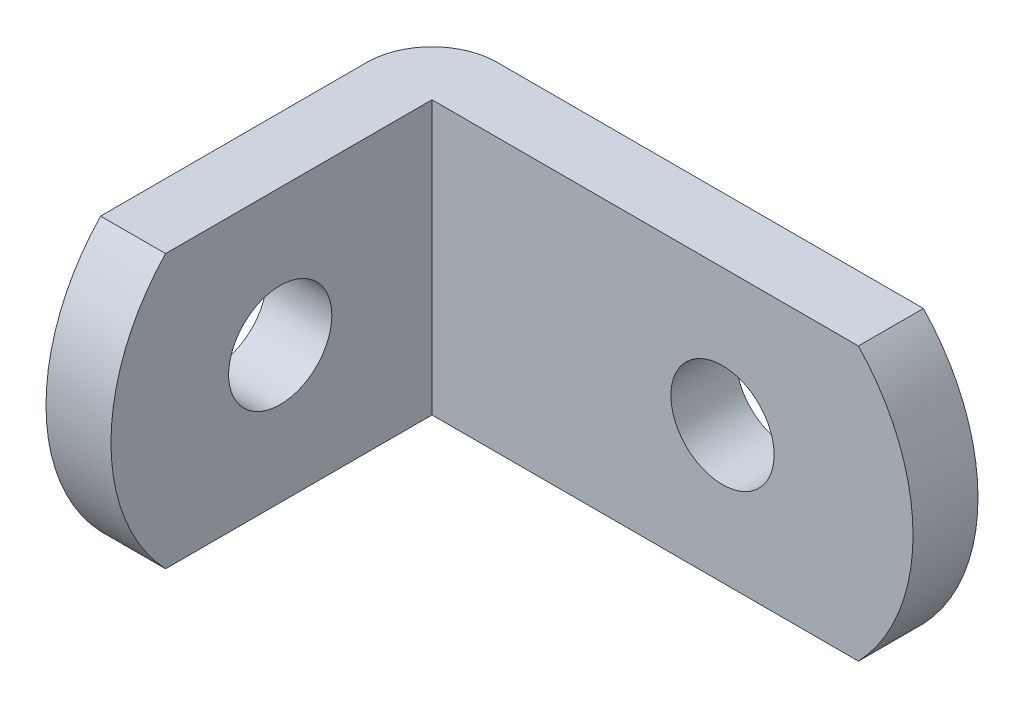
from build123d import *

# Parameters (mm, degrees)
EXTRUDE_THIN1_DEPTH     = 6.35
CUT_EXTRUDE1_DEPTH      = 23.3774
CUT_EXTRUDE1_DEPTH_BACK = 4.0226
SKETCH7_R               = 2.4
CUT_EXTRUDE3_DEPTH      = 4.0226
CUT_EXTRUDE2_DEPTH      = 15.9352
CUT_EXTRUDE2_DEPTH_BACK = 4.0226
SKETCH8_R               = 2.4
CUT_EXTRUDE4_DEPTH      = 4.0226


with BuildPart() as part:
    # Sketch4 → Extrude-Thin1 (new body, symmetric)
    with BuildSketch(Plane(origin=(0, 0, 0), x_dir=(1, 0, 0), z_dir=(0, 1, 0))):
        with BuildLine():
            Line((25.4, 0), (3.0226, 0))
            ThreePointArc((3.0226, 0), (0.885299043, -0.885299043), (0, -3.0226))
            Line((0, -3.0226), (0, -17.9578))
            Line((0, -17.9578), (3.0226, -17.9578))
            Line((3.0226, -17.9578), (3.0226, -3.0226))
            Line((3.0226, -3.0226), (25.4, -3.0226))
            Line((25.4, -3.0226), (25.4, 0))
        make_face()
    extrude(amount=EXTRUDE_THIN1_DEPTH, both=True)

    # Sketch5 → Cut-Extrude1 (cut, two sides)
    with BuildSketch(Plane(origin=(3.0226, 0, 0), x_dir=(0, 0, -1), z_dir=(1, 0, 0))) as cut_extrude1_sk:
        with BuildLine():
            Line((19.030404457, 42.52061468), (-15.4178, 6.35))
            ThreePointArc((-15.4178, 6.35), (-17.9578, 0), (-15.4178, -6.35))
            Line((-15.4178, -6.35), (19.030404457, -42.52061468))
            Line((19.030404457, -42.52061468), (-80.869388468, -42.52061468))
            Line((-80.869388468, -42.52061468), (-80.869388468, 42.52061468))
            Line((-80.869388468, 42.52061468), (19.030404457, 42.52061468))
        make_face()
    extrude(amount=CUT_EXTRUDE1_DEPTH, mode=Mode.SUBTRACT)
    extrude(cut_extrude1_sk.sketch, amount=-CUT_EXTRUDE1_DEPTH_BACK, mode=Mode.SUBTRACT)

    # Sketch7 → Cut-Extrude3 (cut, through all)
    with BuildSketch(Plane(origin=(3.0226, 0, 0), x_dir=(0, 0, -1), z_dir=(1, 0, 0))):
        with Locations((-10.0838, 0)):
            Circle(SKETCH7_R)
    extrude(amount=-CUT_EXTRUDE3_DEPTH, mode=Mode.SUBTRACT)

    # Sketch6 → Cut-Extrude2 (cut, two sides)
    with BuildSketch(Plane.XY.offset(3.0226)) as cut_extrude2_sk:
        with BuildLine():
            Line((-20.10675939, -51.46509736), (22.86, -6.35))
            ThreePointArc((22.86, -6.35), (25.4, 0), (22.86, 6.35))
            Line((22.86, 6.35), (-20.10675939, 51.46509736))
            Line((-20.10675939, 51.46509736), (104.496842842, 51.46509736))
            Line((104.496842842, 51.46509736), (104.496842842, -51.46509736))
            Line((104.496842842, -51.46509736), (-20.10675939, -51.46509736))
        make_face()
    extrude(amount=CUT_EXTRUDE2_DEPTH, mode=Mode.SUBTRACT)
    extrude(cut_extrude2_sk.sketch, amount=-CUT_EXTRUDE2_DEPTH_BACK, mode=Mode.SUBTRACT)

    # Sketch8 → Cut-Extrude4 (cut, through all)
    with BuildSketch(Plane.XY.offset(3.0226)):
        with Locations((16.5354, 0)):
            Circle(SKETCH8_R)
    extrude(amount=-CUT_EXTRUDE4_DEPTH, mode=Mode.SUBTRACT)


solid = part.part
